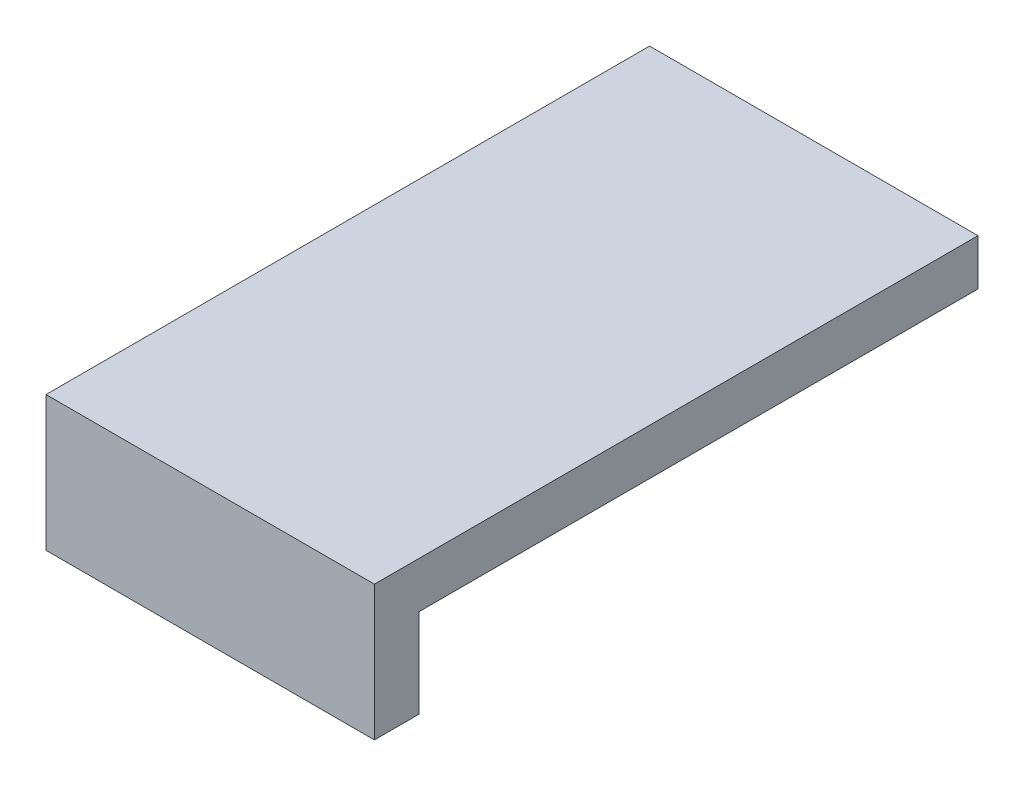
from build123d import *

# Parameters (mm, degrees)
SKETCH1_W           = 18.5
SKETCH1_H           = 34
BOSS_EXTRUDE1_DEPTH = 2.6
SKETCH2_W           = 18.5
SKETCH2_H           = 2.5
BOSS_EXTRUDE2_DEPTH = 5


with BuildPart() as part:
    # Sketch1 → Boss-Extrude1 (new body)
    with BuildSketch(Plane(origin=(0, 0, 0), x_dir=(1, 0, 0), z_dir=(0, 1, 0))):
        Rectangle(SKETCH1_W, SKETCH1_H)
    extrude(amount=BOSS_EXTRUDE1_DEPTH)

    # Sketch2 → Boss-Extrude2 (add)
    with BuildSketch(Plane.XZ):
        with Locations((0, 15.75)):
            Rectangle(SKETCH2_W, SKETCH2_H)
    extrude(amount=BOSS_EXTRUDE2_DEPTH)


solid = part.part
